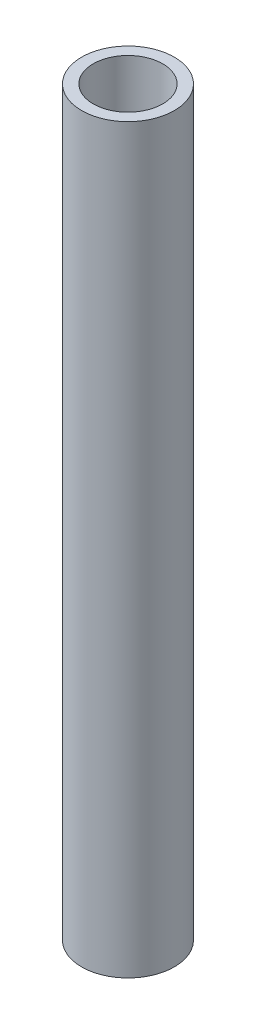
from build123d import *

# Parameters (mm, degrees)
SKETCH1_R           = 1
SKETCH1_R_2         = 0.75
BOSS_EXTRUDE1_DEPTH = 16


with BuildPart() as part:
    # Sketch1 → Boss-Extrude1 (new body)
    with BuildSketch(Plane(origin=(0, 0, 0), x_dir=(1, 0, 0), z_dir=(0, 1, 0))):
        Circle(SKETCH1_R)
        Circle(SKETCH1_R_2, mode=Mode.SUBTRACT)
    extrude(amount=BOSS_EXTRUDE1_DEPTH)


solid = part.part
